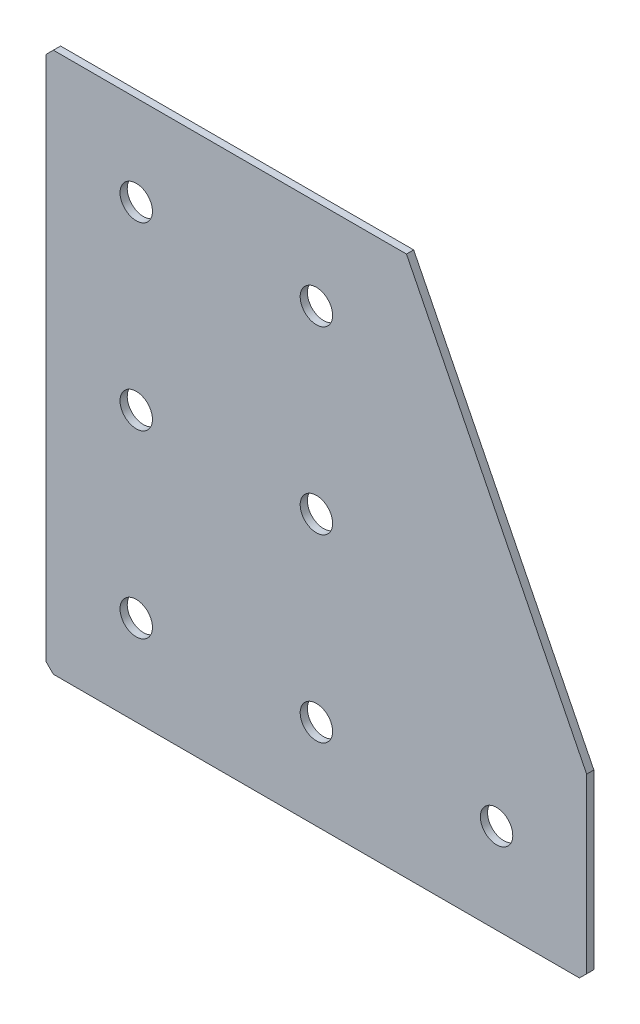
from build123d import *

# Parameters (mm, degrees)
EXTRUDE_1_DEPTH   = 2
HOLE_WIZARD_M81_D = 9
CHAMFER_1_SIZE    = 2


with BuildPart() as part:
    # Эскиз1 → Бобышка-Вытянуть1 (new body)
    with BuildSketch(Plane(origin=(0, 0, 0), x_dir=(1, 0, 0), z_dir=(0, 0, -1))):
        Polygon((0, 0), (0, 150), (150, 150), (150, 100), (100, 0), align=None)
    extrude(amount=EXTRUDE_1_DEPTH)

    # Отверстие с зазором M81 (through all)
    with Locations(Plane(origin=(0, 0, -2), x_dir=(1, 0, 0), z_dir=(0, 0, -1))):
        with Locations((75, 125), (25, 125), (25, 75), (25, 25), (125, 125), (75, 75), (75, 25)):
            Hole(HOLE_WIZARD_M81_D / 2)

    # Фаска1
    chamfer_1_edges = [part.edges().sort_by_distance(p)[0] for p in [
        (0, 0, -1),
        (0, -150, -1),
        (150, -150, -1),
    ]]
    chamfer(chamfer_1_edges, length=CHAMFER_1_SIZE)


solid = part.part
